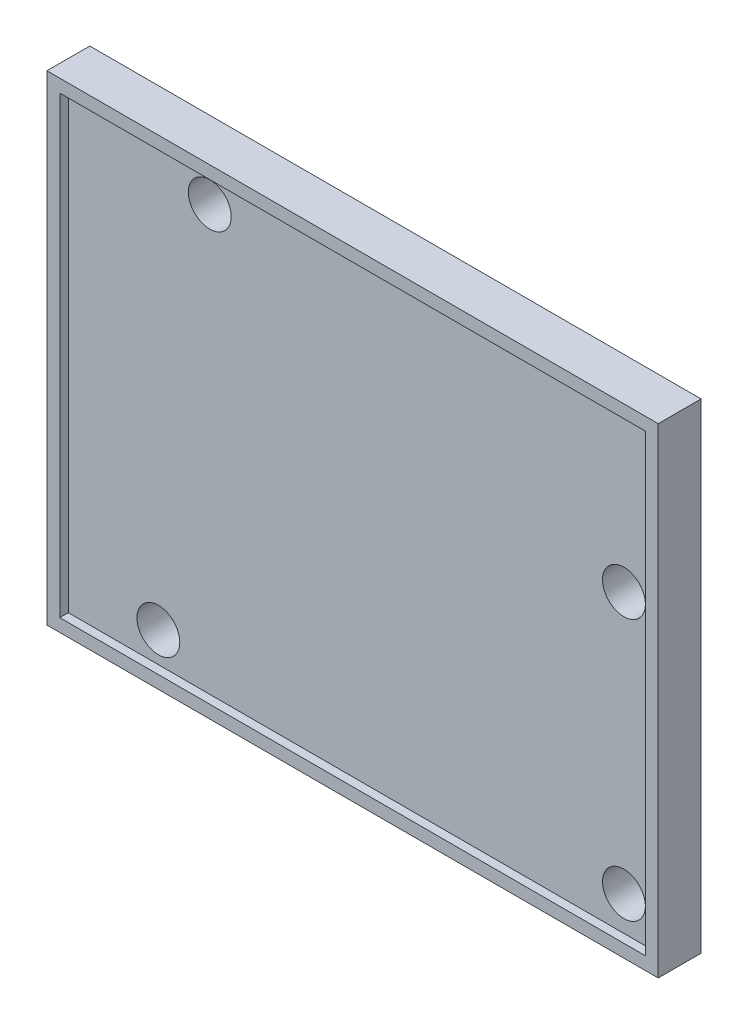
from build123d import *

# Parameters (mm, degrees)
SKETCH1_W           = 71.31
SKETCH1_H           = 56
BOSS_EXTRUDE1_DEPTH = 5
SKETCH2_R           = 2.5
CUT_EXTRUDE1_DEPTH  = 5
SKETCH3_W           = 68.31
SKETCH3_H           = 53
CUT_EXTRUDE2_DEPTH  = 1


with BuildPart() as part:
    # Sketch1 → Boss-Extrude1 (new body)
    with BuildSketch(Plane.XY):
        Rectangle(SKETCH1_W, SKETCH1_H)
    extrude(amount=BOSS_EXTRUDE1_DEPTH)

    # Sketch2 → Cut-Extrude1 (cut)
    with BuildSketch(Plane.XY.offset(5)):
        with Locations((-23.655, -23)):
            Circle(SKETCH2_R)
        with Locations((30.655, 8)):
            Circle(SKETCH2_R)
        with Locations((-17.655, 23)):
            Circle(SKETCH2_R)
        with Locations((30.655, -22.5)):
            Circle(SKETCH2_R)
    extrude(amount=-CUT_EXTRUDE1_DEPTH, mode=Mode.SUBTRACT)

    # Sketch3 → Cut-Extrude2 (cut)
    with BuildSketch(Plane.XY.offset(5)):
        Rectangle(SKETCH3_W, SKETCH3_H)
    extrude(amount=-CUT_EXTRUDE2_DEPTH, mode=Mode.SUBTRACT)


solid = part.part
